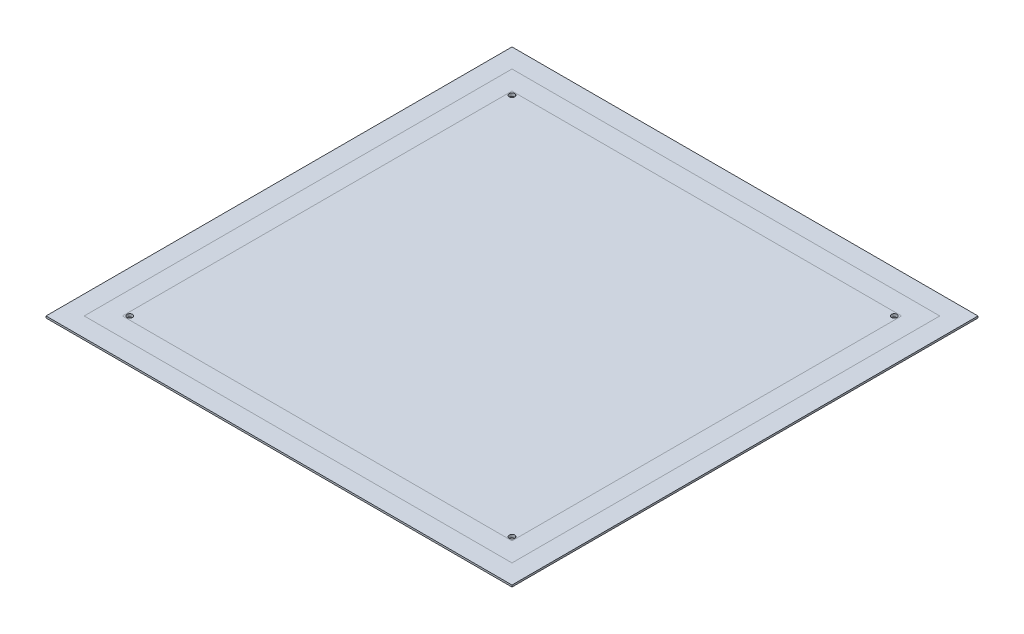
from build123d import *

# Parameters (mm, degrees)
SKETCH1_W                  = 214
SKETCH1_H                  = 214
BOSS_EXTRUDE1_DEPTH        = 1.6
M2_5_CLEARANCE_HOLE1_D     = 3.1
M2_5_CLEARANCE_HOLE1_DEPTH = 11.938
M2_5_CLEARANCE_HOLE1_TIP   = 0.931333959
SKETCH5_W                  = 235
SKETCH5_H                  = 235
SKETCH5_W_2                = 214
SKETCH5_H_2                = 214
BOSS_EXTRUDE2_DEPTH        = 1
SKETCH6_W                  = 256
SKETCH6_H                  = 256
SKETCH6_W_2                = 235
SKETCH6_H_2                = 235
BOSS_EXTRUDE3_DEPTH        = 1


with BuildPart() as part:
    # Sketch1 → Boss-Extrude1 (new body)
    with BuildSketch(Plane(origin=(0, 0, 0), x_dir=(1, 0, 0), z_dir=(0, 1, 0))):
        Rectangle(SKETCH1_W, SKETCH1_H)
    extrude(amount=BOSS_EXTRUDE1_DEPTH)

    # M2.5 Clearance Hole1
    with Locations(Plane(origin=(0, 1.6, 0), x_dir=(1, 0, 0), z_dir=(0, 1, 0))):
        with Locations((-105, 105), (105, 105), (105, -105), (-105, -105)):
            Hole(M2_5_CLEARANCE_HOLE1_D / 2, depth=M2_5_CLEARANCE_HOLE1_DEPTH)
            with Locations((0, 0, -(M2_5_CLEARANCE_HOLE1_DEPTH + M2_5_CLEARANCE_HOLE1_TIP / 2))):  # 118° drill point
                Cone(0, M2_5_CLEARANCE_HOLE1_D / 2, M2_5_CLEARANCE_HOLE1_TIP, mode=Mode.SUBTRACT)


with BuildPart() as body_2:
    # Sketch5 → Boss-Extrude2 (new body)
    with BuildSketch(Plane(origin=(0, 1.6, 0), x_dir=(1, 0, 0), z_dir=(0, 1, 0))):
        Rectangle(SKETCH5_W, SKETCH5_H)
        Rectangle(SKETCH5_W_2, SKETCH5_H_2, mode=Mode.SUBTRACT)
    extrude(amount=-BOSS_EXTRUDE2_DEPTH)


with BuildPart() as body_3:
    # Sketch6 → Boss-Extrude3 (new body)
    with BuildSketch(Plane(origin=(0, 1.6, 0), x_dir=(1, 0, 0), z_dir=(0, 1, 0))):
        Rectangle(SKETCH6_W, SKETCH6_H)
        Rectangle(SKETCH6_W_2, SKETCH6_H_2, mode=Mode.SUBTRACT)
    extrude(amount=-BOSS_EXTRUDE3_DEPTH)


solid = Compound([part.part, body_2.part, body_3.part])
